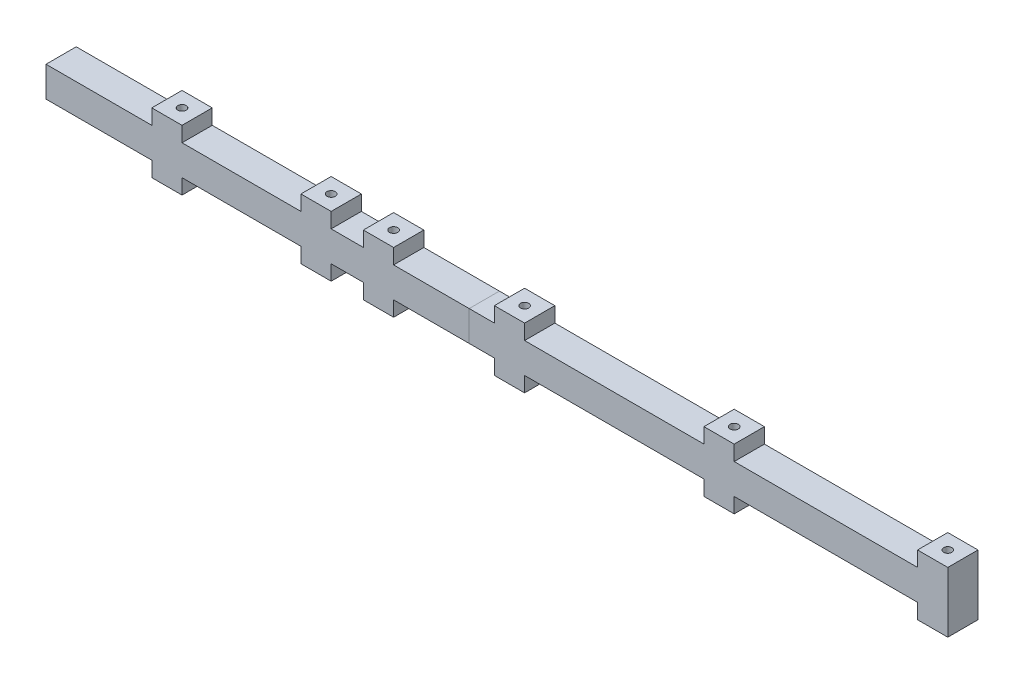
from build123d import *

# Parameters (mm, degrees)
SKETCH1_W                  = 400
SKETCH1_H                  = 15
BOSS_EXTRUDE1_DEPTH        = 7.5
F_4_1_4_1_DIAMETER_HOLE1_D = 4.1
SKETCH4_R                  = 2.05
BOSS_EXTRUDE2_DEPTH        = 2.5
SKETCH5_W                  = 15
SKETCH5_H                  = 15
SKETCH5_R                  = 2.05
BOSS_EXTRUDE3_DEPTH        = 15
SKETCH6_W                  = 15
SKETCH6_H                  = 15
BOSS_EXTRUDE5_DEPTH        = 50
SKETCH8_W                  = 15
SKETCH8_H                  = 15
CUT_EXTRUDE1_DEPTH         = 2.5
SPLIT1_SURFACE_1_BACK      = 449.755
SPLIT1_SURFACE_1_DEPTH     = 899.51
SPLIT1_SURFACE_2_BACK      = 449.755
SPLIT1_SURFACE_2_DEPTH     = 899.51


with BuildPart() as part:
    # Sketch1 → Boss-Extrude1 (new, symmetric)
    with BuildSketch(Plane(origin=(0, 0, 0), x_dir=(1, 0, 0), z_dir=(0, 1, 0))):
        Rectangle(SKETCH1_W, SKETCH1_H)
    extrude(amount=BOSS_EXTRUDE1_DEPTH, both=True)

    # Ø4.1 (4.1) Diameter Hole1 (through all)
    with Locations(Plane.XZ.offset(7.5)):
        with Locations((-190, 0), (-116, 0), (-85, 0), (-20, 0), (84, 0), (190, 0)):
            Hole(F_4_1_4_1_DIAMETER_HOLE1_D / 2)

    # Sketch4 → Boss-Extrude2 (add, symmetric)
    with BuildSketch(Plane(origin=(0, 0, 0), x_dir=(1, 0, 0), z_dir=(0, 1, 0))):
        with Locations(Location((-116, 0, 0), (0, 0, 90))):
            Circle(SKETCH4_R)
    extrude(amount=BOSS_EXTRUDE2_DEPTH, both=True)

    # Sketch5 → Boss-Extrude3 (add, symmetric)
    with BuildSketch(Plane(origin=(0, 0, 0), x_dir=(1, 0, 0), z_dir=(0, 1, 0))):
        with Locations((-190, 0)):
            Rectangle(SKETCH5_W, SKETCH5_H)
        with Locations(Location((-190, 0, 0), (0, 0, 270))):
            Circle(SKETCH5_R, mode=Mode.SUBTRACT)
        with Locations((-116, 0)):
            Rectangle(SKETCH5_W, SKETCH5_H)
        with Locations(Location((-116, 0, 0), (0, 0, 270))):
            Circle(SKETCH5_R, mode=Mode.SUBTRACT)
        with Locations((-85, 0)):
            Rectangle(SKETCH5_W, SKETCH5_H)
        with Locations(Location((-85, 0, 0), (0, 0, 270))):
            Circle(SKETCH5_R, mode=Mode.SUBTRACT)
        with Locations((-20, 0)):
            Rectangle(SKETCH5_W, SKETCH5_H)
        with Locations(Location((-20, 0, 0), (0, 0, 270))):
            Circle(SKETCH5_R, mode=Mode.SUBTRACT)
        with Locations((84, 0)):
            Rectangle(SKETCH5_W, SKETCH5_H)
        with Locations(Location((84, 0, 0), (0, 0, 270))):
            Circle(SKETCH5_R, mode=Mode.SUBTRACT)
        with Locations((190, 0)):
            Rectangle(SKETCH5_W, SKETCH5_H)
        with Locations(Location((190, 0, 0), (0, 0, 270))):
            Circle(SKETCH5_R, mode=Mode.SUBTRACT)
    extrude(amount=BOSS_EXTRUDE3_DEPTH, both=True)

    # Sketch6 → Boss-Extrude5 (add)
    with BuildSketch(Plane.ZY.offset(200)):
        Rectangle(SKETCH6_W, SKETCH6_H)
    extrude(amount=BOSS_EXTRUDE5_DEPTH)

    # Sketch8 → Cut-Extrude1 (cut)
    with BuildSketch(Plane(origin=(200, 0, 0), x_dir=(0, 0, -1), z_dir=(1, 0, 0))):
        Rectangle(SKETCH8_W, SKETCH8_H)
    extrude(amount=-CUT_EXTRUDE1_DEPTH, mode=Mode.SUBTRACT)


with BuildPart() as body_2:
    # Split1: the piece behind the surface
    add(part.part)
    # Split1 surface: a surface, the sketch's curves swept straight by 899.51 mm
    with BuildLine(Plane.XY.offset(7.5).offset(-SPLIT1_SURFACE_1_BACK), mode=Mode.PRIVATE) as split1_surface_1_path:
        Line((-40, 7.5), (-40, -7.5))
    split1_surface_1 = Shell.extrude(split1_surface_1_path.wire(), (0 * SPLIT1_SURFACE_1_DEPTH, 0 * SPLIT1_SURFACE_1_DEPTH, 1 * SPLIT1_SURFACE_1_DEPTH))
    split(bisect_by=split1_surface_1, keep=Keep.BOTTOM)


with BuildPart() as part_1:
    add(part.part)

    # Split1: split by a surface, the side it looks to stays
    # Split1 surface: a surface, the sketch's curves swept straight by 899.51 mm
    with BuildLine(Plane.XY.offset(7.5).offset(-SPLIT1_SURFACE_2_BACK), mode=Mode.PRIVATE) as split1_surface_2_path:
        Line((-40, 7.5), (-40, -7.5))
    split1_surface_2 = Shell.extrude(split1_surface_2_path.wire(), (0 * SPLIT1_SURFACE_2_DEPTH, 0 * SPLIT1_SURFACE_2_DEPTH, 1 * SPLIT1_SURFACE_2_DEPTH))
    split(bisect_by=split1_surface_2, keep=Keep.TOP)


solid = Compound([body_2.part, part_1.part])
